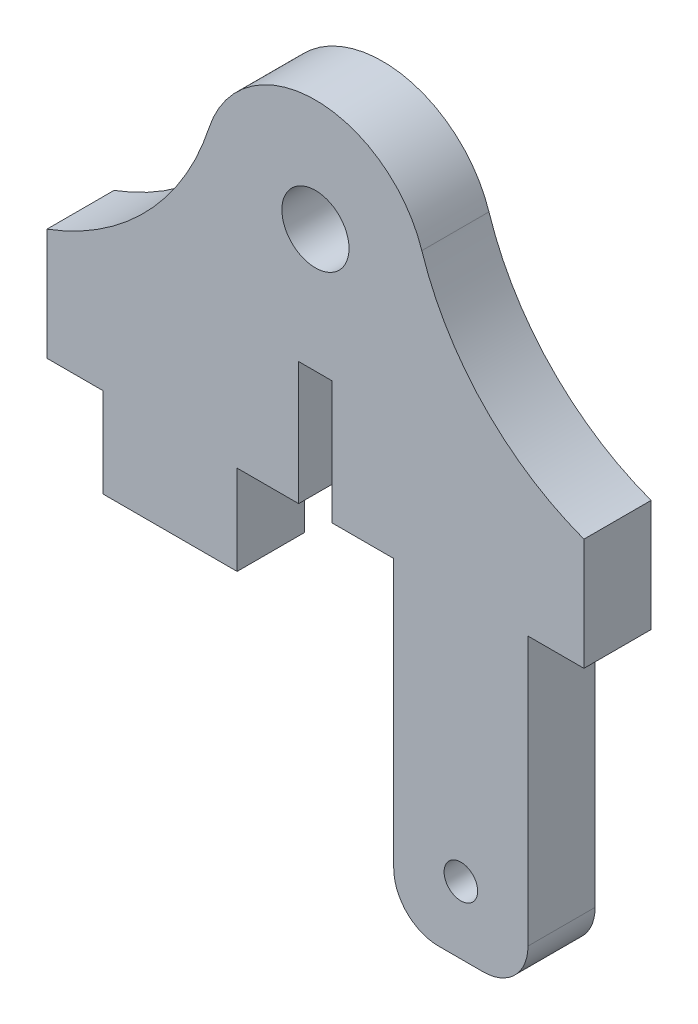
from build123d import *

# Parameters (mm, degrees)
SKETCH1_R           = 1.5
SKETCH1_R_2         = 0.75
BOSS_EXTRUDE1_DEPTH = 3
SKETCH2_W           = 2.5
SKETCH2_H           = 4
CUT_EXTRUDE1_DEPTH  = 10
SKETCH3_W           = 3.5
SKETCH3_H           = 4
BOSS_EXTRUDE2_DEPTH = 3
SKETCH4_W           = 2.5
SKETCH4_H           = 14
CUT_EXTRUDE2_DEPTH  = 10
FILLET1_R           = 2


with BuildPart() as part:
    # Sketch1 → Boss-Extrude1 (new body)
    with BuildSketch(Plane.XY):
        with BuildLine():
            Line((-0.75, -11), (-7, -11))
            Line((-7, -11), (-7, -15))
            Line((-7, -15), (-12, -15))
            Line((-12, -15), (-12, -11))
            Line((-12, -11), (-12, -6))
            ThreePointArc((-12, -6), (-7.512319363, -3.05842228), (-4.755323166, 1.544960058))
            ThreePointArc((-4.755323166, 1.544960058), (0, 5), (4.755323166, 1.544960058))
            ThreePointArc((4.755323166, 1.544960058), (7.512319363, -3.05842228), (12, -6))
            Line((12, -6), (12, -25))
            Line((12, -25), (3.5, -25))
            Line((3.5, -25), (3.5, -11))
            Line((3.5, -11), (0.75, -11))
            Line((0.75, -11), (0.75, -5.5))
            Line((0.75, -5.5), (-0.75, -5.5))
            Line((-0.75, -5.5), (-0.75, -11))
        make_face()
        Circle(SKETCH1_R, mode=Mode.SUBTRACT)
        with Locations((6.5, -22)):
            Circle(SKETCH1_R_2, mode=Mode.SUBTRACT)
    extrude(amount=BOSS_EXTRUDE1_DEPTH)

    # Sketch2 → Cut-Extrude1 (cut)
    with BuildSketch(Plane.XY.offset(3)):
        with Locations((-10.75, -13)):
            Rectangle(SKETCH2_W, SKETCH2_H)
    extrude(amount=-CUT_EXTRUDE1_DEPTH, mode=Mode.SUBTRACT)

    # Sketch3 → Boss-Extrude2 (add)
    with BuildSketch(Plane.XY.offset(3)):
        with Locations((-5.25, -13)):
            Rectangle(SKETCH3_W, SKETCH3_H)
    extrude(amount=-BOSS_EXTRUDE2_DEPTH)

    # Sketch4 → Cut-Extrude2 (cut)
    with BuildSketch(Plane.XY.offset(3)):
        with Locations((10.75, -18)):
            Rectangle(SKETCH4_W, SKETCH4_H)
    extrude(amount=-CUT_EXTRUDE2_DEPTH, mode=Mode.SUBTRACT)

    # Fillet1
    fillet1_edges = [part.edges().sort_by_distance(p)[0] for p in [
        (3.5, -25, 1.5),
        (9.5, -25, 1.5),
    ]]
    fillet(fillet1_edges, radius=FILLET1_R)


solid = part.part
